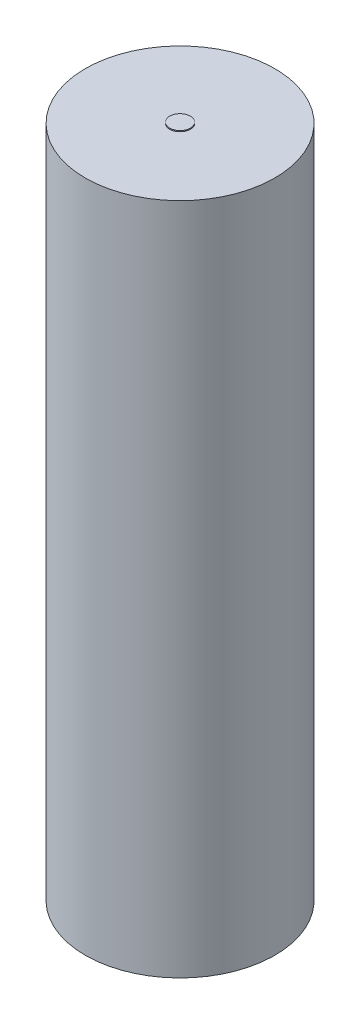
from build123d import *

# Parameters (mm, degrees)
SKETCH1_R           = 9.15
BOSS_EXTRUDE1_DEPTH = 65
SKETCH2_R           = 1
BOSS_EXTRUDE2_DEPTH = 0.1
SKETCH3_R           = 1
BOSS_EXTRUDE3_DEPTH = 0.1


with BuildPart() as part:
    # Sketch1 → Boss-Extrude1 (new body)
    with BuildSketch(Plane(origin=(0, 0, 0), x_dir=(1, 0, 0), z_dir=(0, 1, 0))):
        Circle(SKETCH1_R)
    extrude(amount=-BOSS_EXTRUDE1_DEPTH)

    # Sketch2 → Boss-Extrude2 (add)
    with BuildSketch(Plane(origin=(0, 0, 0), x_dir=(1, 0, 0), z_dir=(0, 1, 0))):
        Circle(SKETCH2_R)
    extrude(amount=BOSS_EXTRUDE2_DEPTH)

    # Sketch3 → Boss-Extrude3 (add)
    with BuildSketch(Plane.XZ.offset(65)):
        Circle(SKETCH3_R)
    extrude(amount=BOSS_EXTRUDE3_DEPTH)


solid = part.part
